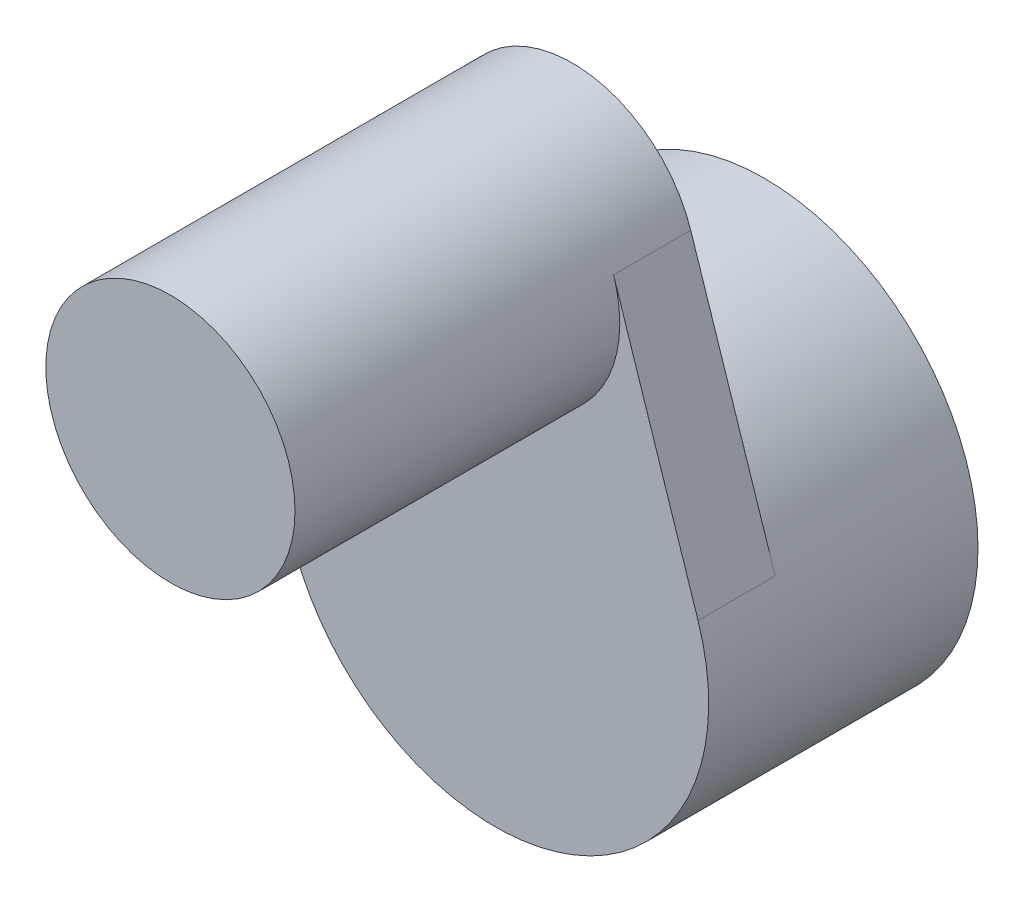
from build123d import *

# Parameters (mm, degrees)
SKETCH1_R           = 3.37312
SKETCH1_R_2         = 2.33426
BOSS_EXTRUDE1_DEPTH = 4.2545
SKETCH2_R           = 0.4699
BOSS_EXTRUDE2_DEPTH = 1.2192
SKETCH3_R           = 2.33426
BOSS_EXTRUDE3_DEPTH = 1.5621
SKETCH4_R           = 1.9685
BOSS_EXTRUDE5_DEPTH = 5.1308


with BuildPart() as part:
    # Sketch1 → Boss-Extrude1 (new body)
    with BuildSketch(Plane.XY):
        Circle(SKETCH1_R)
        Circle(SKETCH1_R_2, mode=Mode.SUBTRACT)
    extrude(amount=BOSS_EXTRUDE1_DEPTH)

    # Sketch2 → Boss-Extrude2 (add)
    with BuildSketch(Plane.XY.offset(4.2545)):
        with BuildLine():
            ThreePointArc((1.87014753, 5.114443216), (0, 6.4685), (-1.87014753, 5.114443216))
            Line((-1.87014753, 5.114443216), (-3.204588284, 1.052878181))
            ThreePointArc((-3.204588284, 1.052878181), (0, 3.37312), (3.204588284, 1.052878181))
            Line((3.204588284, 1.052878181), (1.87014753, 5.114443216))
        make_face()
        with Locations((0, 4.5)):
            Circle(SKETCH2_R, mode=Mode.SUBTRACT)
    extrude(amount=-BOSS_EXTRUDE2_DEPTH)

    # Sketch3 → Boss-Extrude3 (add)
    with BuildSketch(Plane.XY.offset(4.2545)):
        Circle(SKETCH3_R)
    extrude(amount=-BOSS_EXTRUDE3_DEPTH)

    # Sketch4 → Boss-Extrude5 (add)
    with BuildSketch(Plane.XY.offset(4.2545)):
        with Locations((0, 4.5)):
            Circle(SKETCH4_R)
    extrude(amount=BOSS_EXTRUDE5_DEPTH)


solid = part.part
